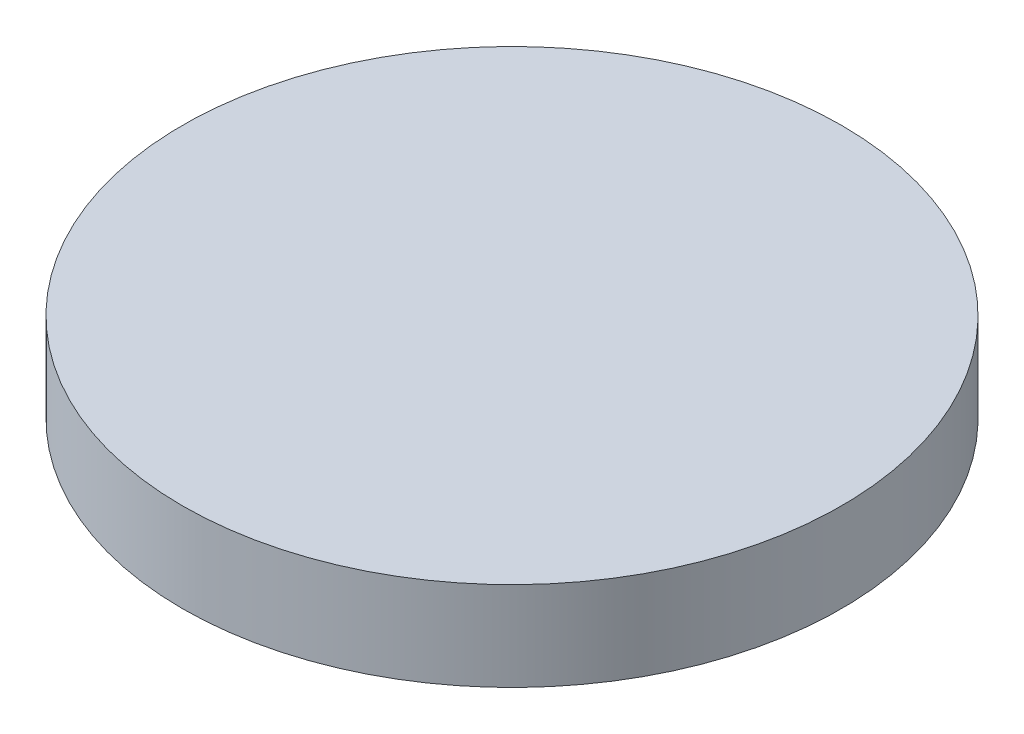
from build123d import *

# Parameters (mm, degrees)
SKETCH1_R           = 37
BOSS_EXTRUDE1_DEPTH = 10


with BuildPart() as part:
    # Sketch1 → Boss-Extrude1 (new body)
    with BuildSketch(Plane(origin=(0, 0, 0), x_dir=(1, 0, 0), z_dir=(0, 1, 0))):
        with Locations((-140.116350288, 35.189814303)):
            Circle(SKETCH1_R)
    extrude(amount=BOSS_EXTRUDE1_DEPTH)


solid = part.part
